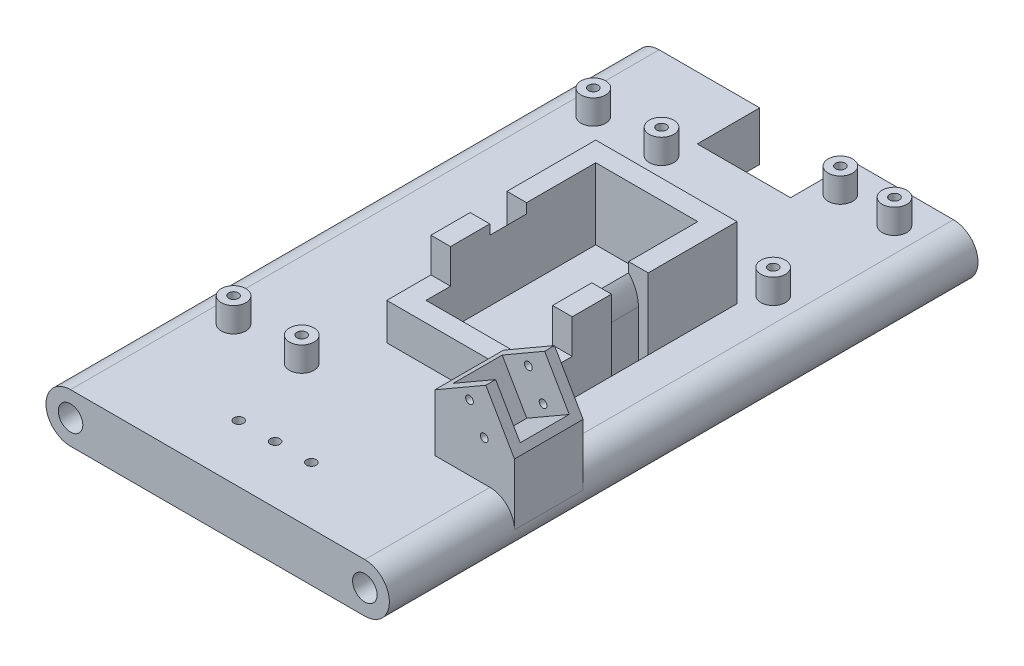
from build123d import *

# Parameters (mm, degrees)
BOSS_EXTRUDE1_DEPTH = 152.4
SKETCH3_R           = 3.175
CUT_EXTRUDE1_DEPTH  = 159.876949241
BOSS_EXTRUDE2_START = -34.925
BOSS_EXTRUDE2_DEPTH = 12.7
BOSS_EXTRUDE3_DEPTH = 2.54
BOSS_EXTRUDE4_START = -12.7
BOSS_EXTRUDE4_DEPTH = 2.54
SKETCH7_R           = 1
CUT_EXTRUDE2_DEPTH  = 25.4
SKETCH8_W           = 36.576
SKETCH8_H           = 54.102
SKETCH8_W_2         = 26.416
SKETCH8_H_2         = 43.942
BOSS_EXTRUDE5_DEPTH = 18.415
SKETCH9_W           = 11.43
SKETCH9_H           = 8.89
CUT_EXTRUDE3_DEPTH  = 50.8
SKETCH10_R          = 3.175
SKETCH10_R_2        = 1.25
BOSS_EXTRUDE6_DEPTH = 6.35
SKETCH12_R          = 1.25
CUT_EXTRUDE4_DEPTH  = 161.317919845
SKETCH13_W          = 24.13
SKETCH13_H          = 16.166041667
CUT_EXTRUDE5_DEPTH  = 322.365846996
CUT_EXTRUDE6_START  = -69.85
CUT_EXTRUDE6_DEPTH  = 9.525
SKETCH15_R          = 1.25
CUT_EXTRUDE7_DEPTH  = 218.016479851


with BuildPart() as part:
    # Sketch2 → Boss-Extrude1 (new body)
    with BuildSketch(Plane.XY):
        with BuildLine():
            Line((-38.1, 6.35), (38.1, 6.35))
            ThreePointArc((38.1, 6.35), (44.45, 0), (38.1, -6.35))
            Line((38.1, -6.35), (-38.1, -6.35))
            ThreePointArc((-38.1, -6.35), (-44.45, 0), (-38.1, 6.35))
        make_face()
    extrude(amount=BOSS_EXTRUDE1_DEPTH)

    # Sketch3 → Cut-Extrude1 (cut, through all)
    with BuildSketch(Plane(origin=(0, 0, 0), x_dir=(-1, 0, 0), z_dir=(0, 0, -1))):
        with Locations((-38.1, 0)):
            Circle(SKETCH3_R)
        with Locations((38.1, 0)):
            Circle(SKETCH3_R)
    extrude(amount=-CUT_EXTRUDE1_DEPTH, mode=Mode.SUBTRACT)

    # Sketch5 → Boss-Extrude2 (add)
    with BuildSketch(Plane.XY.offset(152.4).offset(BOSS_EXTRUDE2_START)):
        with BuildLine():
            Line((26.040402296, 22.366781694), (32.390402296, 11.368259066))
            Line((32.390402296, 11.368259066), (43.388924924, 17.718259066))
            Line((43.388924924, 17.718259066), (44.45, 15.880423124))
            Line((44.45, 15.880423124), (44.45, 0))
            ThreePointArc((44.45, 0), (42.590128061, 4.490128061), (38.1, 6.35))
            Line((38.1, 6.35), (23.84069777, 6.35))
            Line((23.84069777, 6.35), (23.84069777, 21.096781694))
            Line((23.84069777, 21.096781694), (26.040402296, 22.366781694))
        make_face()
    extrude(amount=-BOSS_EXTRUDE2_DEPTH)

    # Sketch6 → Boss-Extrude3 (add)
    with BuildSketch(Plane.XY.offset(117.475)):
        with BuildLine():
            Line((23.84069777, 6.35), (38.1, 6.35))
            ThreePointArc((38.1, 6.35), (42.590128061, 4.490128061), (44.45, 0))
            Line((44.45, 0), (44.45, 15.880423124))
            Line((44.45, 15.880423124), (37.038924924, 28.716781694))
            Line((37.038924924, 28.716781694), (23.84069777, 21.096781694))
            Line((23.84069777, 21.096781694), (23.84069777, 6.35))
        make_face()
    extrude(amount=BOSS_EXTRUDE3_DEPTH)

    # Sketch6_2 → Boss-Extrude4 (add)
    with BuildSketch(Plane.XY.offset(117.475).offset(BOSS_EXTRUDE4_START)):
        with BuildLine():
            Line((23.84069777, 6.35), (38.1, 6.35))
            ThreePointArc((38.1, 6.35), (42.590128061, 4.490128061), (44.45, 0))
            Line((44.45, 0), (44.45, 15.880423124))
            Line((44.45, 15.880423124), (37.038924924, 28.716781694))
            Line((37.038924924, 28.716781694), (23.84069777, 21.096781694))
            Line((23.84069777, 21.096781694), (23.84069777, 6.35))
        make_face()
    extrude(amount=-BOSS_EXTRUDE4_DEPTH)

    # Sketch7 → Cut-Extrude2 (cut)
    with BuildSketch(Plane(origin=(-48.529047444, -83.623680275, 120.015), x_dir=(1, 0, 0), z_dir=(0, 0, 1))):
        with Locations(Location((85.148711054, 100.366643867, 0), (0, 0, 180))):
            Circle(SKETCH7_R)
        with Locations(Location((81.338711054, 106.965757444, 0), (0, 0, 180))):
            Circle(SKETCH7_R)
    extrude(amount=-CUT_EXTRUDE2_DEPTH, mode=Mode.SUBTRACT)

    # Sketch8 → Boss-Extrude5 (add)
    with BuildSketch(Plane(origin=(0, 6.35, 0), x_dir=(1, 0, 0), z_dir=(0, 1, 0))):
        with Locations((10.63269777, -73.914)):
            Rectangle(SKETCH8_W, SKETCH8_H)
        with Locations((10.63269777, -73.914)):
            Rectangle(SKETCH8_W_2, SKETCH8_H_2, mode=Mode.SUBTRACT)
    extrude(amount=BOSS_EXTRUDE5_DEPTH)

    # Sketch9 → Cut-Extrude3 (cut)
    with BuildSketch(Plane(origin=(28.92069777, -83.623680275, -42.409589959), x_dir=(0, 0, -1), z_dir=(1, 0, 0))):
        with Locations((-137.659589959, 103.943680275)):
            Rectangle(SKETCH9_W, SKETCH9_H)
    extrude(amount=-CUT_EXTRUDE3_DEPTH, mode=Mode.SUBTRACT)

    # Sketch10 → Boss-Extrude6 (add)
    with BuildSketch(Plane(origin=(0, 6.35, 0), x_dir=(1, 0, 0), z_dir=(0, 1, 0))):
        with Locations(Location((31.765, -8.938, 0), (0, 0, 270))):
            Circle(SKETCH10_R)
        with Locations(Location((31.765, -8.938, 0), (0, 0, 270))):
            Circle(SKETCH10_R_2, mode=Mode.SUBTRACT)
    boss_extrude6 = extrude(amount=BOSS_EXTRUDE6_DEPTH)

    # Sketch12 → Cut-Extrude4 (cut, through all)
    with BuildSketch(Plane(origin=(0, 6.35, 0), x_dir=(1, 0, 0), z_dir=(0, 1, 0))):
        with Locations(Location((31.765, -8.938, 0), (0, 0, 270))):
            Circle(SKETCH12_R)
    cut_extrude4 = extrude(amount=-CUT_EXTRUDE4_DEPTH, mode=Mode.SUBTRACT)

    # Sketch-Pattern1: Boss-Extrude6, Cut-Extrude4 at 7 more places
    with Locations((0, 0, 31.4), (-14, 0, 31.4), (-14, 0, 0), (-45.840002, 0, 14.477001), (-63.489998, 0, 14.477001), (-63.489998, 0, 107.627), (-45.840002, 0, 107.627)):
        add(boss_extrude6)
        add(cut_extrude4, mode=Mode.SUBTRACT)

    # Sketch13 → Cut-Extrude5 (cut, through all)
    with BuildSketch(Plane(origin=(55.039702575, 6.35, 304.758156205), x_dir=(-1, 0, 0), z_dir=(0, 1, 0))):
        with Locations((55.039702575, -296.675135372)):
            Rectangle(SKETCH13_W, SKETCH13_H)
    extrude(amount=-CUT_EXTRUDE5_DEPTH, mode=Mode.SUBTRACT)

    # Sketch14 → Cut-Extrude6 (cut)
    with BuildSketch(Plane(origin=(-48.529047444, -83.623680275, 0), x_dir=(-1, 0, 0), z_dir=(0, 0, -1)).offset(CUT_EXTRUDE6_START)):
        with BuildLine():
            Line((-74.909745214, 99.498680275), (-74.909745214, 77.273680275))
            Line((-74.909745214, 77.273680275), (-77.449745214, 77.273680275))
            Line((-77.449745214, 77.273680275), (-77.449745214, 108.388680275))
            Line((-77.449745214, 108.388680275), (-72.369745214, 108.388680275))
            Line((-72.369745214, 108.388680275), (-72.369745214, 105.848680275))
            ThreePointArc((-72.369745214, 105.848680275), (-74.251194346, 102.918259928), (-74.909745214, 99.498680275))
        make_face()
        with BuildLine():
            Line((-45.953745214, 105.848680275), (-45.953745214, 108.388680275))
            Line((-45.953745214, 108.388680275), (-40.873745214, 108.388680275))
            Line((-40.873745214, 108.388680275), (-40.873745214, 77.273680275))
            Line((-40.873745214, 77.273680275), (-43.413745214, 77.273680275))
            Line((-43.413745214, 77.273680275), (-43.413745214, 99.498680275))
            ThreePointArc((-43.413745214, 99.498680275), (-44.072296083, 102.918259928), (-45.953745214, 105.848680275))
        make_face()
    extrude(amount=-CUT_EXTRUDE6_DEPTH, mode=Mode.SUBTRACT)

    # Sketch15 → Cut-Extrude7 (cut, through all)
    with BuildSketch(Plane(origin=(-48.529047444, 6.35, -42.409589959), x_dir=(1, 0, 0), z_dir=(0, 1, 0))):
        with Locations(Location((57.927047444, -179.950589959, 0), (0, 0, 270))):
            Circle(SKETCH15_R)
        with Locations(Location((48.529047444, -179.950589959, 0), (0, 0, 270))):
            Circle(SKETCH15_R)
        with Locations(Location((39.131047444, -179.950589959, 0), (0, 0, 270))):
            Circle(SKETCH15_R)
    extrude(amount=-CUT_EXTRUDE7_DEPTH, mode=Mode.SUBTRACT)


solid = part.part
